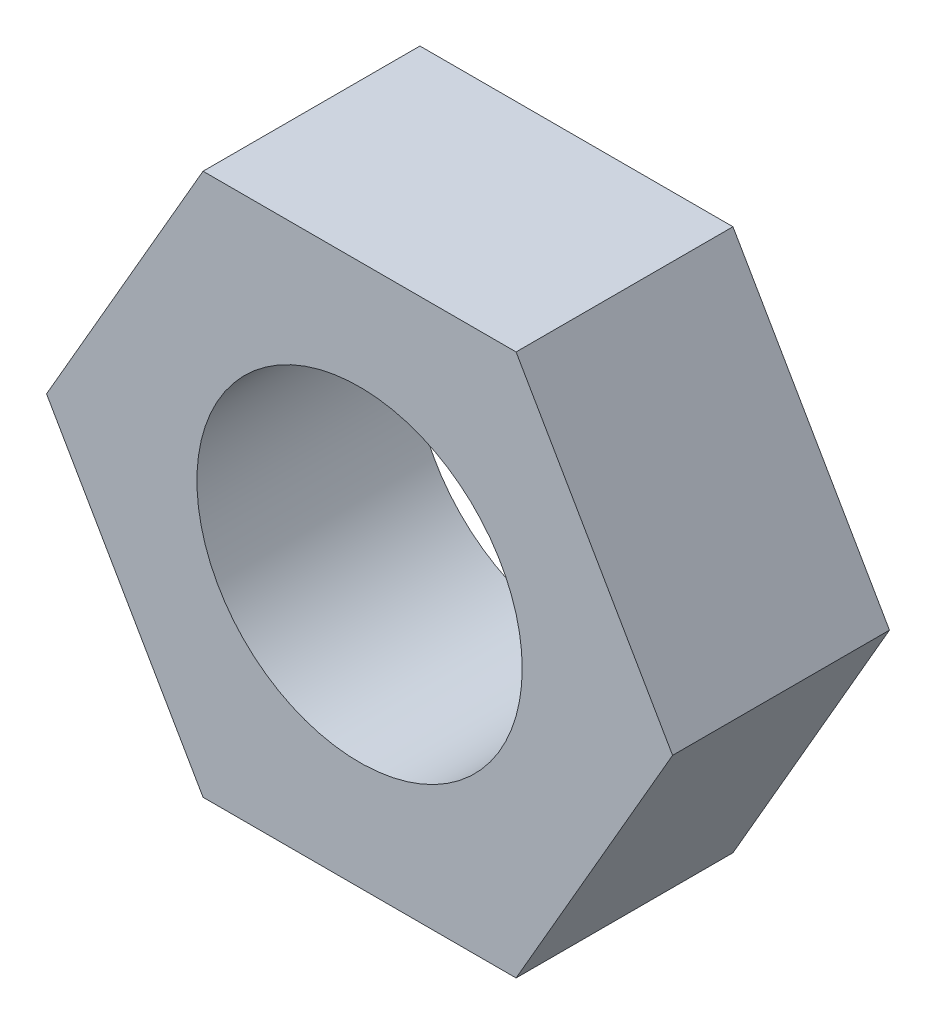
from build123d import *

# Parameters (mm, degrees)
EXTRUSION1_DEPTH = 4
SKETCH2_R        = 3
THREAD1_DEPTH    = 4


with BuildPart() as part:
    # Sketch1 → Extrusion1 (new body)
    with BuildSketch(Plane.XY):
        Polygon((5.773502692, 0), (2.886751346, 5), (-2.886751346, 5), (-5.773502692, 0), (-2.886751346, -5), (2.886751346, -5), align=None)
    extrude(amount=-EXTRUSION1_DEPTH)

    # Sketch2 → Thread1 (cut)
    with BuildSketch(Plane.XY):
        Circle(SKETCH2_R)
    extrude(amount=-THREAD1_DEPTH, mode=Mode.SUBTRACT)


solid = part.part
